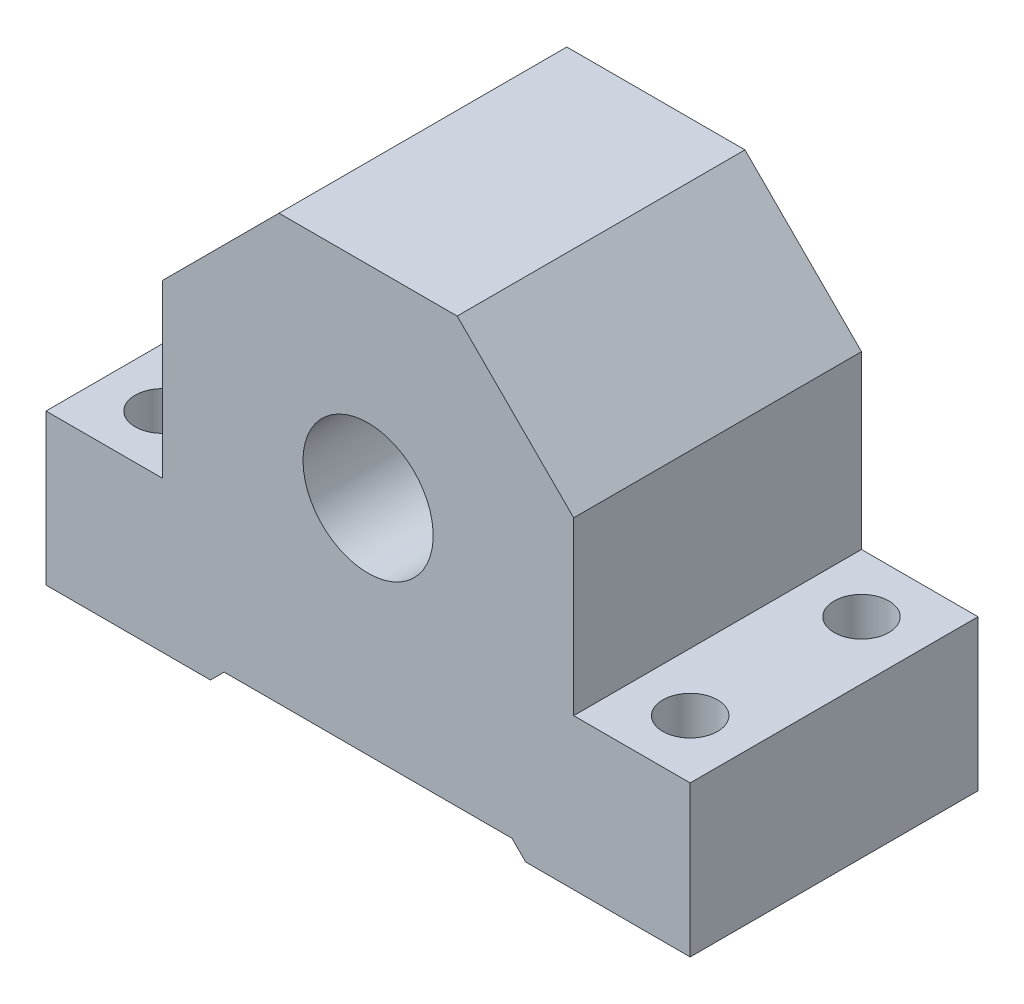
from build123d import *

# Parameters (mm, degrees)
DODANIE_WYCI_GNI_CIE1_DEPTH = 42
SZKIC2_R                    = 9.5
WYTNIJ_WYCI_GNI_CIE1_DEPTH  = 42
SZKIC3_R                    = 4
WYTNIJ_WYCI_GNI_CIE2_DEPTH  = 22


with BuildPart() as part:
    # Szkic1 → Dodanie-wyciągnięcie1 (new body)
    with BuildSketch(Plane.XY):
        Polygon((-47, 11), (-30, 11), (-30, 36), (-13, 53), (13, 53), (30, 36), (30, 11), (47, 11), (47, -11), (23, -11), (21, -9), (-21, -9), (-23, -11), (-47, -11), align=None)
    extrude(amount=DODANIE_WYCI_GNI_CIE1_DEPTH)

    # Szkic2 → Wytnij-wyciągnięcie1 (cut)
    with BuildSketch(Plane(origin=(0, 0, 0), x_dir=(-1, 0, 0), z_dir=(0, 0, -1))):
        with Locations((0, 23.5)):
            Circle(SZKIC2_R)
    extrude(amount=-WYTNIJ_WYCI_GNI_CIE1_DEPTH, mode=Mode.SUBTRACT)

    # Szkic3 → Wytnij-wyciągnięcie2 (cut)
    with BuildSketch(Plane(origin=(0, 11, 0), x_dir=(1, 0, 0), z_dir=(0, 1, 0))):
        with Locations((-38.5, -8.5)):
            Circle(SZKIC3_R)
        with Locations((-38.5, -33.5)):
            Circle(SZKIC3_R)
        with Locations((38.5, -33.5)):
            Circle(SZKIC3_R)
        with Locations((38.5, -8.5)):
            Circle(SZKIC3_R)
    extrude(amount=-WYTNIJ_WYCI_GNI_CIE2_DEPTH, mode=Mode.SUBTRACT)


solid = part.part
